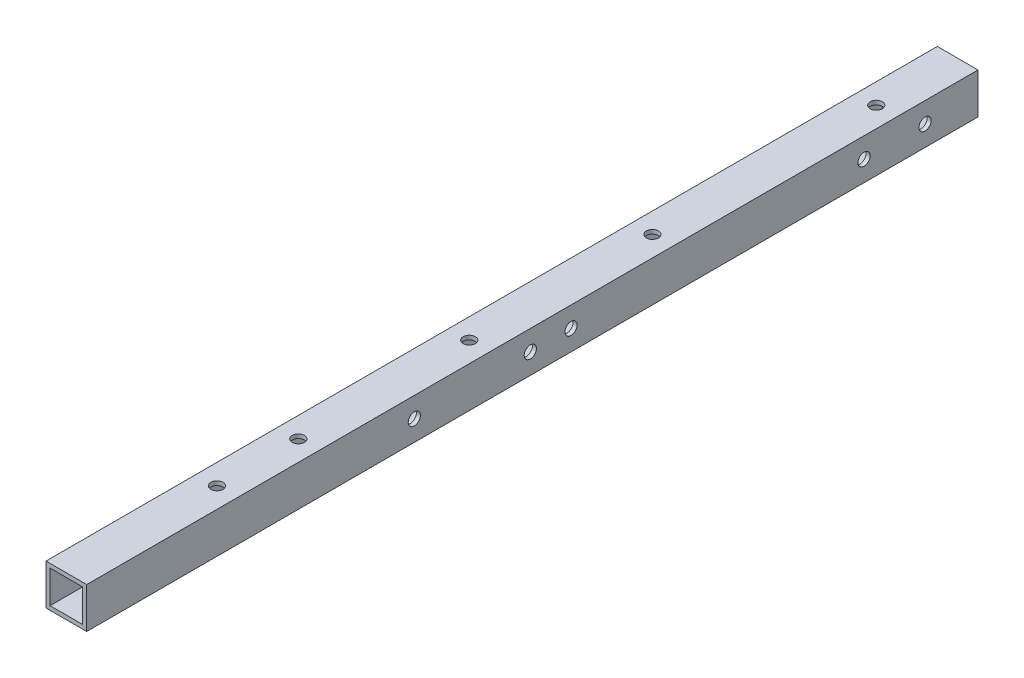
from build123d import *

# Parameters (mm, degrees)
SKETCH_1_W          = 10
SKETCH_1_H          = 10
SKETCH_1_W_2        = 8
SKETCH_1_H_2        = 8
EXTRUDE_1_DEPTH     = 219
SKETCH_2_R          = 1.5
CUT_EXTRUDE_1_DEPTH = 10
SKETCH_3_R          = 1.5
CUT_EXTRUDE_2_DEPTH = 11


with BuildPart() as part:
    # 草图1 → 拉伸-薄壁1 (new body)
    with BuildSketch(Plane.XY):
        Rectangle(SKETCH_1_W, SKETCH_1_H)
        Rectangle(SKETCH_1_W_2, SKETCH_1_H_2, mode=Mode.SUBTRACT)
    extrude(amount=EXTRUDE_1_DEPTH)

    # 草图2 → 切除-拉伸1 (cut)
    with BuildSketch(Plane(origin=(0, 5, 0), x_dir=(1, 0, 0), z_dir=(0, 1, 0))):
        with Locations((0, -182)):
            Circle(SKETCH_2_R)
        with Locations((0, -20)):
            Circle(SKETCH_2_R)
        with Locations((0, -120)):
            Circle(SKETCH_2_R)
        with Locations((0, -162)):
            Circle(SKETCH_2_R)
        with Locations((0, -75)):
            Circle(SKETCH_2_R)
    extrude(amount=-CUT_EXTRUDE_1_DEPTH, mode=Mode.SUBTRACT)

    # 草图3 → 切除-拉伸2 (cut, through all)
    with BuildSketch(Plane(origin=(5, 0, 0), x_dir=(0, 0, -1), z_dir=(1, 0, 0))):
        with Locations((-13, 0)):
            Circle(SKETCH_3_R)
        with Locations((-28, 0)):
            Circle(SKETCH_3_R)
        with Locations((-138.5, 0)):
            Circle(SKETCH_3_R)
        with Locations((-100, 0)):
            Circle(SKETCH_3_R)
        with Locations((-110, 0)):
            Circle(SKETCH_3_R)
    extrude(amount=-CUT_EXTRUDE_2_DEPTH, mode=Mode.SUBTRACT)


solid = part.part
